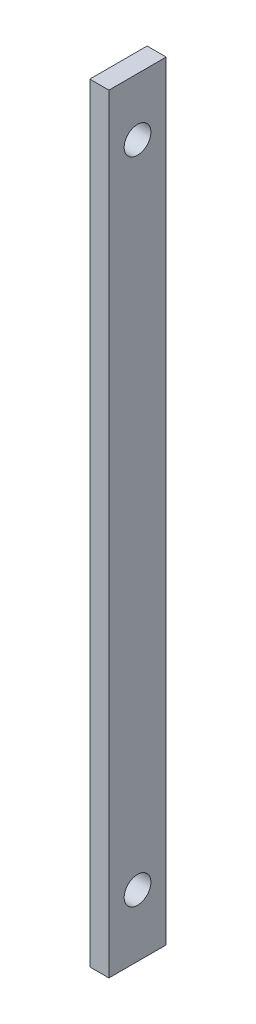
from build123d import *

# Parameters (mm, degrees)
SKETCH1_W                   = 15
SKETCH1_H                   = 201.245586551
BOSS_EXTRUDE1_DEPTH         = 5
TAP_DRILL_FOR_M8X1_0_TAP1_D = 7


with BuildPart() as part:
    # Sketch1 → Boss-Extrude1 (new body)
    with BuildSketch(Plane(origin=(0, 0, 0), x_dir=(0, 0, -1), z_dir=(1, 0, 0))):
        with Locations((-36.342736335, -53.087805706)):
            Rectangle(SKETCH1_W, SKETCH1_H)
    extrude(amount=BOSS_EXTRUDE1_DEPTH)

    # Tap Drill for M8x1.0 Tap1 (through all)
    with Locations(Plane(origin=(5, 0, 0), x_dir=(0, 0, -1), z_dir=(1, 0, 0))):
        with Locations((-36.342736335, 32.53498757), (-36.342736335, -137.470598981)):
            Hole(TAP_DRILL_FOR_M8X1_0_TAP1_D / 2)


solid = part.part
